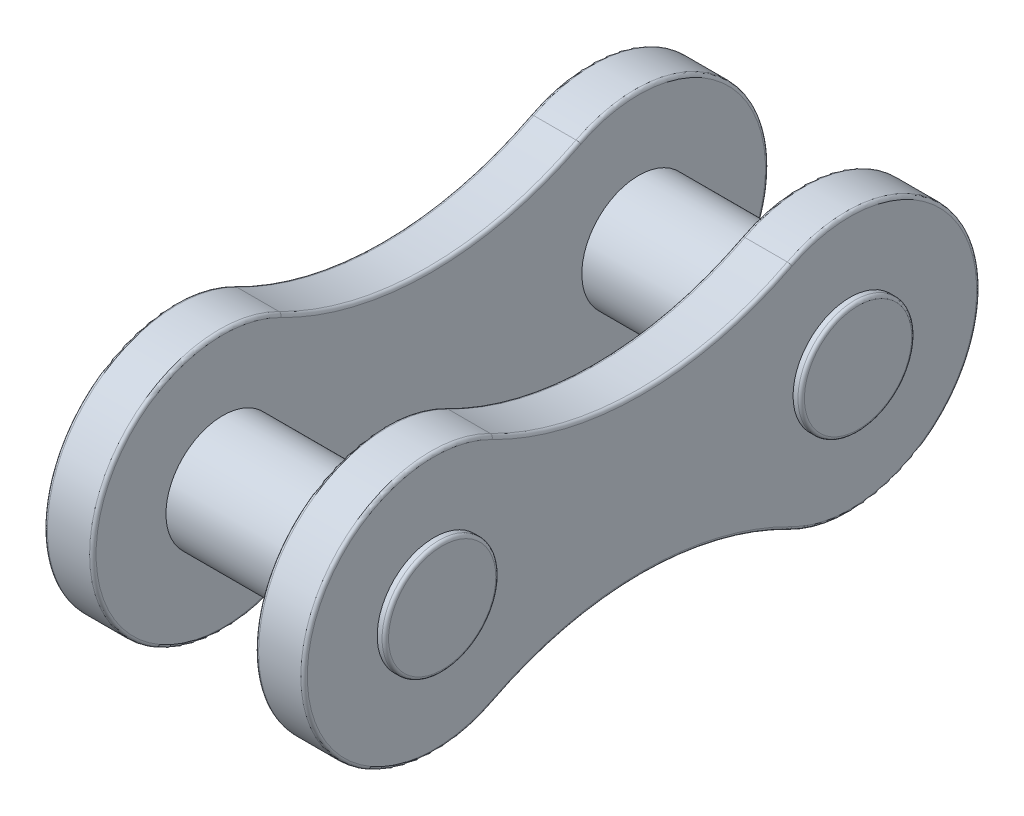
from build123d import *

# Parameters (mm, degrees)
BOSS_EXTRUDE2_START = 2.5
SKETCH5_R           = 1.75
BOSS_EXTRUDE2_DEPTH = 1.5
BOSS_EXTRUDE3_START = -2.5
SKETCH6_R           = 1.75
BOSS_EXTRUDE3_DEPTH = 1.5
SKETCH7_R           = 1.75
BOSS_EXTRUDE4_DEPTH = 4.25
FILLET1_R           = 0.1


with BuildPart() as part:
    # Sketch5 → Boss-Extrude2 (new body)
    with BuildSketch(Plane(origin=(0, 0, 0), x_dir=(0, 0, -1), z_dir=(1, 0, 0)).offset(BOSS_EXTRUDE2_START)):
        with BuildLine():
            ThreePointArc((-4.570357143, 3.557793374), (-10.3985, 0), (-4.570357143, -3.557793374))
            ThreePointArc((-4.570357143, -3.557793374), (0, -2.45227681), (4.570357143, -3.557793374))
            ThreePointArc((4.570357143, -3.557793374), (10.3985, 0), (4.570357143, 3.557793374))
            ThreePointArc((4.570357143, 3.557793374), (0, 2.45227681), (-4.570357143, 3.557793374))
        make_face()
        with Locations((-6.3985, 0)):
            Circle(SKETCH5_R, mode=Mode.SUBTRACT)
        with Locations((6.3985, 0)):
            Circle(SKETCH5_R, mode=Mode.SUBTRACT)
    extrude(amount=BOSS_EXTRUDE2_DEPTH)



with BuildPart() as body_2:
    # Sketch6 → Boss-Extrude3 (new body)
    with BuildSketch(Plane(origin=(0, 0, 0), x_dir=(0, 0, -1), z_dir=(1, 0, 0)).offset(BOSS_EXTRUDE3_START)):
        with BuildLine():
            ThreePointArc((-4.570357143, 3.557793374), (0, 2.45227681), (4.570357143, 3.557793374))
            ThreePointArc((4.570357143, 3.557793374), (10.3985, 0), (4.570357143, -3.557793374))
            ThreePointArc((4.570357143, -3.557793374), (0, -2.45227681), (-4.570357143, -3.557793374))
            ThreePointArc((-4.570357143, -3.557793374), (-10.3985, 0), (-4.570357143, 3.557793374))
        make_face()
        with Locations((6.3985, 0)):
            Circle(SKETCH6_R, mode=Mode.SUBTRACT)
        with Locations((-6.3985, 0)):
            Circle(SKETCH6_R, mode=Mode.SUBTRACT)
    extrude(amount=-BOSS_EXTRUDE3_DEPTH)


with BuildPart() as part_1:
    add(part.part)

    add(body_2.part)  # Boss-Extrude4 merges body 2
    # Sketch7 → Boss-Extrude4 (add, symmetric)
    with BuildSketch(Plane(origin=(0, 0, 0), x_dir=(0, 0, -1), z_dir=(1, 0, 0))):
        with Locations((6.3985, 0)):
            Circle(SKETCH7_R)
        with Locations((-6.3985, 0)):
            Circle(SKETCH7_R)
    extrude(amount=BOSS_EXTRUDE4_DEPTH, both=True)

    # Fillet1
    fillet1_edges = [part_1.edges().sort_by_distance(p)[0] for p in [
        (4, -2.45227681, 0),
        (4, 0, -10.3985),
        (-4.25, 0, -4.6485),
        (4.25, 0, -4.6485),
        (-4, 0, 10.3985),
        (-4, 2.45227681, 0),
        (-4, 0, -10.3985),
        (-4, -2.45227681, 0),
        (-2.5, 0, 10.3985),
        (-2.5, -2.45227681, 0),
        (-2.5, 0, -10.3985),
        (-2.5, 2.45227681, 0),
        (-4.25, 0, 8.1485),
        (4.25, 0, 8.1485),
        (4, 2.45227681, 0),
        (2.5, 0, -10.3985),
        (2.5, -2.45227681, 0),
        (2.5, 0, 10.3985),
        (2.5, 2.45227681, 0),
        (4, 0, 10.3985),
    ]]
    fillet(fillet1_edges, radius=FILLET1_R)


solid = part_1.part
